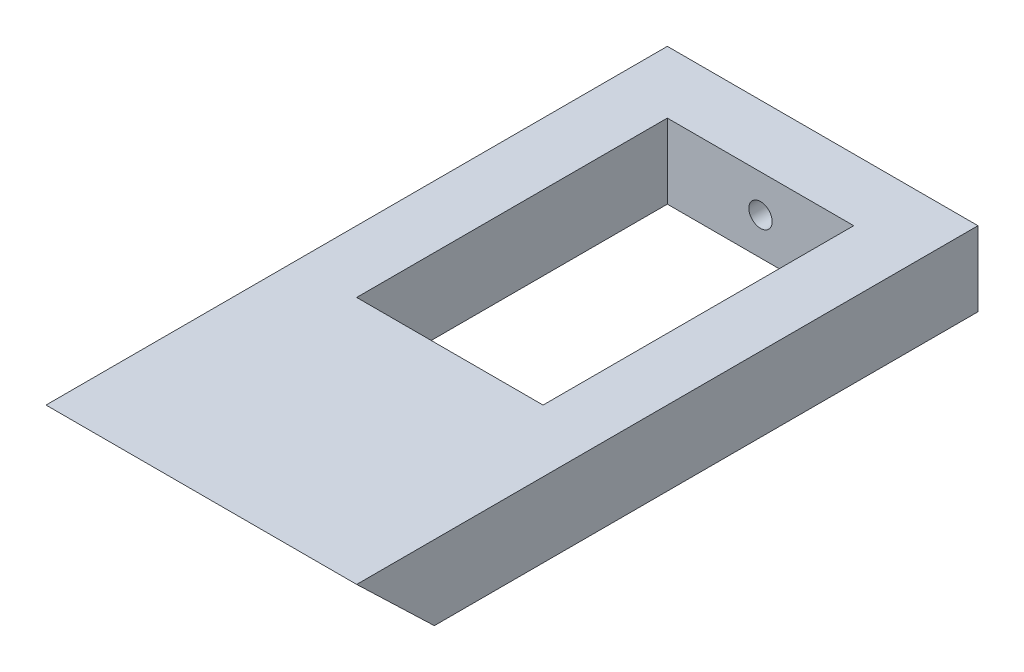
from build123d import *

# Parameters (mm, degrees)
SKETCH1_W           = 25.4
SKETCH1_H           = 50.8
BOSS_EXTRUDE1_DEPTH = 6.096
CUT_EXTRUDE2_DEPTH  = 26.4
SKETCH4_W           = 15.24
SKETCH4_H           = 25.4
CUT_EXTRUDE3_DEPTH  = 7.096
SKETCH5_R           = 2.286
CUT_EXTRUDE4_DEPTH  = 2.54
CUT_EXTRUDE5_REACH  = 52.8
SKETCH6_R           = 0.9525


with BuildPart() as part:
    # Sketch1 → Boss-Extrude1 (new body)
    with BuildSketch(Plane(origin=(0, 0, 0), x_dir=(1, 0, 0), z_dir=(0, 1, 0))):
        Rectangle(SKETCH1_W, SKETCH1_H)
    extrude(amount=BOSS_EXTRUDE1_DEPTH)

    # Sketch3 → Cut-Extrude2 (cut, through all)
    with BuildSketch(Plane(origin=(12.7, 0, 0), x_dir=(0, 0, -1), z_dir=(1, 0, 0))):
        Polygon((-25.4, 6.096), (-25.4, 0), (-19.05, 0), align=None)
    extrude(amount=-CUT_EXTRUDE2_DEPTH, mode=Mode.SUBTRACT)

    # Sketch4 → Cut-Extrude3 (cut, through all)
    with BuildSketch(Plane.XZ):
        with Locations((0, -7.62)):
            Rectangle(SKETCH4_W, SKETCH4_H)
    extrude(amount=-CUT_EXTRUDE3_DEPTH, mode=Mode.SUBTRACT)

    # Sketch5 → Cut-Extrude4 (cut)
    with BuildSketch(Plane(origin=(0, 0, 5.08), x_dir=(-1, 0, 0), z_dir=(0, 0, -1))):
        with Locations((-3.81, 3.302)):
            Circle(SKETCH5_R)
        with Locations((3.81, 3.302)):
            Circle(SKETCH5_R)
    extrude(amount=-CUT_EXTRUDE4_DEPTH, mode=Mode.SUBTRACT)

    # Sketch6 → Cut-Extrude5 (cut, up to next)
    with BuildSketch(Plane(origin=(0, 0, -25.4), x_dir=(-1, 0, 0), z_dir=(0, 0, -1)), mode=Mode.PRIVATE) as cut_extrude5_sk1:
        with Locations((0, 3.048)):
            Circle(SKETCH6_R)
    cut_extrude5_tool1 = extrude(cut_extrude5_sk1.sketch, amount=-CUT_EXTRUDE5_REACH, mode=Mode.PRIVATE) & part.part
    add(cut_extrude5_tool1.solids().sort_by_distance((0, 3.048, -25.4))[0], mode=Mode.SUBTRACT)


solid = part.part
